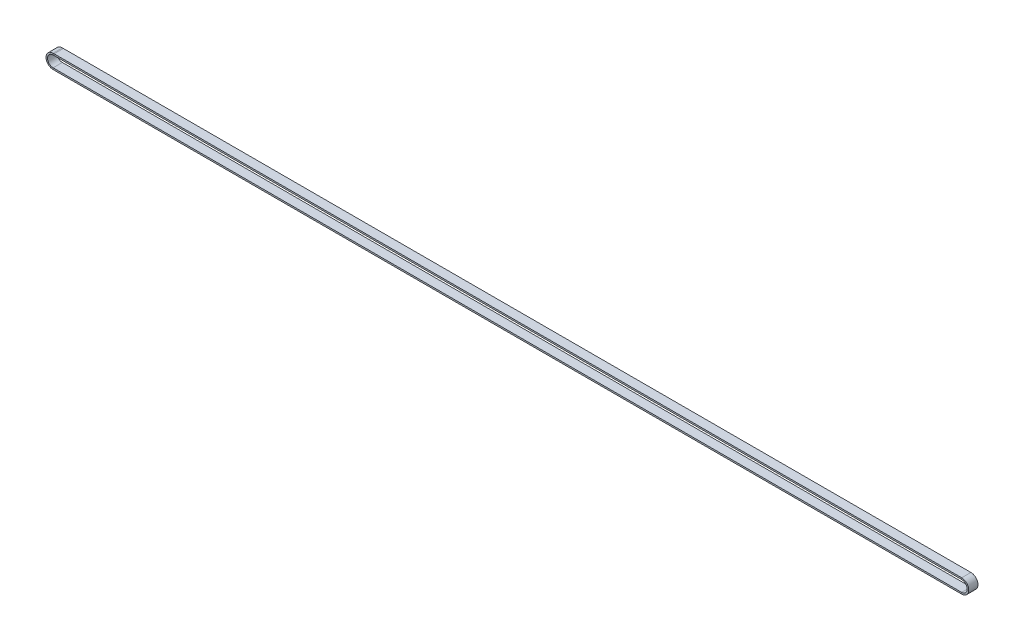
from build123d import *

# Parameters (mm, degrees)
SKETCH3_W = 9
SKETCH3_H = 1.5


with BuildPart() as part:
    # Sweep1: sweep along a path in Sketch2
    with BuildLine(Plane.XY.offset(-150.483366658)) as sweep1_path:
        Line((-1, 148.379342702), (883.52063783, 148.379342702))
        ThreePointArc((883.52063783, 148.379342702), (890.42063783, 141.479342703), (883.52063783, 134.579342702))
        Line((883.52063783, 134.579342702), (-1, 134.579342702))
        ThreePointArc((-1, 134.579342702), (-7.9, 141.479342702), (-1, 148.379342702))
    # Sketch3 → Sweep1 (sweep)
    with BuildSketch(Plane(origin=(0, 0, 0), x_dir=(0, 0, -1), z_dir=(1, 0, 0))):
        with Locations((145.983366658, 147.629342702)):
            Rectangle(SKETCH3_W, SKETCH3_H)
    sweep(path=sweep1_path.line)


solid = part.part
